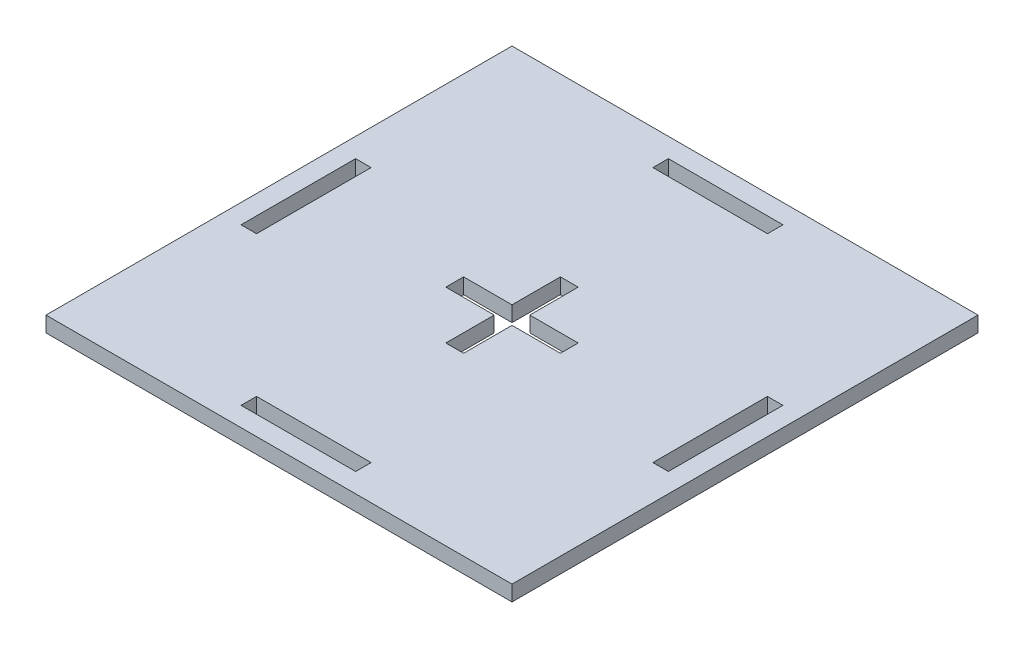
from build123d import *

# Parameters (mm, degrees)
CROQUIS1_W              = 60.2
CROQUIS1_H              = 60.2
SALIENTE_EXTRUIR2_DEPTH = 2
CROQUIS1_5_W            = 14.8
CROQUIS1_5_H            = 2
CROQUIS1_5_W_2          = 2
CROQUIS1_5_H_2          = 14.8
CORTAR_EXTRUIR1_DEPTH   = 10


with BuildPart() as part:
    # Croquis1 → Saliente-Extruir2 (new body)
    with BuildSketch(Plane(origin=(0, 0, 0), x_dir=(1, 0, 0), z_dir=(0, 1, 0))):
        with Locations((30.1, -30.1)):
            Rectangle(CROQUIS1_W, CROQUIS1_H)
    extrude(amount=-SALIENTE_EXTRUIR2_DEPTH)

    # Croquis1_5 → Cortar-Extruir1 (cut)
    with BuildSketch(Plane(origin=(0, 0, 0), x_dir=(1, 0, 0), z_dir=(0, 1, 0))):
        with Locations((30.1, -56.7)):
            Rectangle(CROQUIS1_5_W, CROQUIS1_5_H)
        with Locations((30.1, -3.5)):
            Rectangle(CROQUIS1_5_W, CROQUIS1_5_H)
        with Locations((3.5, -30.1)):
            Rectangle(CROQUIS1_5_W_2, CROQUIS1_5_H_2)
        with Locations((56.7, -30.1)):
            Rectangle(CROQUIS1_5_W_2, CROQUIS1_5_H_2)
        Polygon((28.95, -22.7), (28.95, -28.95), (22.7, -28.95), (22.7, -31.25), (28.95, -31.25), (28.95, -37.5), (31.25, -37.5), (31.25, -31.25), (37.5, -31.25), (37.5, -28.95), (31.25, -28.95), (31.25, -22.7), align=None)
    extrude(amount=-CORTAR_EXTRUIR1_DEPTH, mode=Mode.SUBTRACT)


solid = part.part
